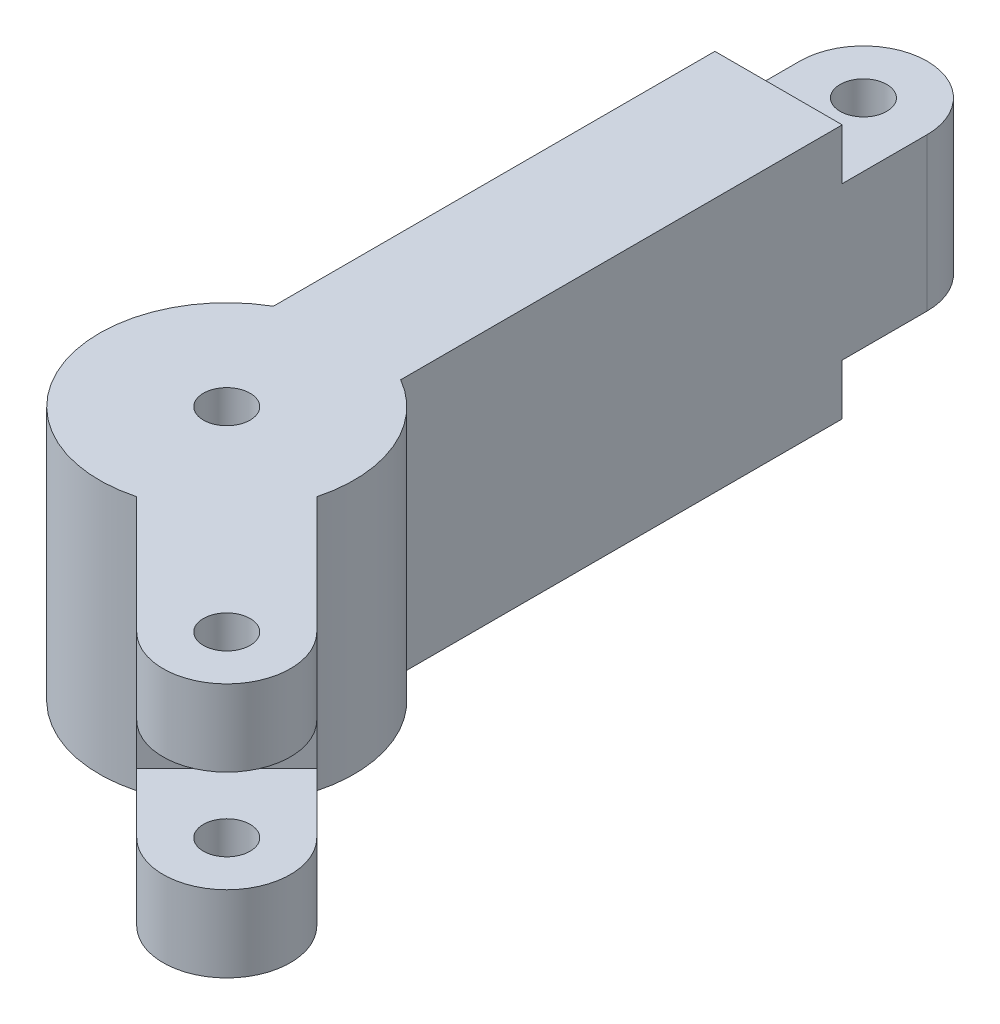
from build123d import *

# Parameters (mm, degrees)
SKETCH1_R           = 2.75
BOSS_EXTRUDE1_DEPTH = 30
SKETCH2_W           = 10
SKETCH2_H           = 6
CUT_EXTRUDE1_DEPTH  = 55
CUT_EXTRUDE2_DEPTH  = 17


with BuildPart() as part:
    # Sketch1 → Boss-Extrude1 (new body)
    with BuildSketch(Plane(origin=(0, 0, 0), x_dir=(1, 0, 0), z_dir=(0, 1, 0))):
        with BuildLine():
            Line((7.5, 12.990381057), (7.5, 75))
            ThreePointArc((7.5, 75), (0, 82.5), (-7.5, 75))
            Line((-7.5, 75), (-7.5, 12.990381057))
            ThreePointArc((-7.5, 12.990381057), (-13.858192988, -5.740251485), (3.882285677, -14.488887394))
            Line((3.882285677, -14.488887394), (17.67766953, -28.284271247))
            ThreePointArc((17.67766953, -28.284271247), (28.284271247, -28.284271247), (28.284271247, -17.67766953))
            Line((28.284271247, -17.67766953), (14.488887394, -3.882285677))
            ThreePointArc((14.488887394, -3.882285677), (13.858192988, 5.740251485), (7.5, 12.990381057))
        make_face()
        Circle(SKETCH1_R, mode=Mode.SUBTRACT)
        with Locations((22.980970389, -22.980970389)):
            Circle(SKETCH1_R, mode=Mode.SUBTRACT)
        with Locations((0, 75)):
            Circle(SKETCH1_R, mode=Mode.SUBTRACT)
    extrude(amount=BOSS_EXTRUDE1_DEPTH)

    # Sketch2 → Cut-Extrude1 (cut)
    with BuildSketch(Plane(origin=(7.5, 0, 0), x_dir=(0, 0, -1), z_dir=(1, 0, 0))):
        Polygon((75, 30), (75, 24), (88.340353556, 24), (88.340353556, 42.222756781), (65, 42.222756781), (65, 30), align=None)
        Polygon((88.340353556, 6), (75, 6), (75, 0), (65, 0), (65, -8.682673162), (88.340353556, -8.682673162), align=None)
        with Locations((70, 3)):
            Rectangle(SKETCH2_W, SKETCH2_H)
        with Locations((70, 27)):
            Rectangle(SKETCH2_W, SKETCH2_H)
    extrude(amount=-CUT_EXTRUDE1_DEPTH, mode=Mode.SUBTRACT)

    # Sketch3 → Cut-Extrude2 (cut)
    with BuildSketch(Plane(origin=(5.303300859, 0, -5.303300859), x_dir=(-0.707106781, 0, -0.707106781), z_dir=(0.707106781, 0, -0.707106781))):
        Polygon((-32.5, 21), (-32.5, 15), (-32.5, 9), (-22.5, 9), (-22.5, 21), align=None)
        Polygon((-32.5, 9), (-32.5, 15), (-32.5, 21), (-50.580242044, 21), (-50.580242044, 9), align=None)
    extrude(amount=-CUT_EXTRUDE2_DEPTH, mode=Mode.SUBTRACT)


solid = part.part
